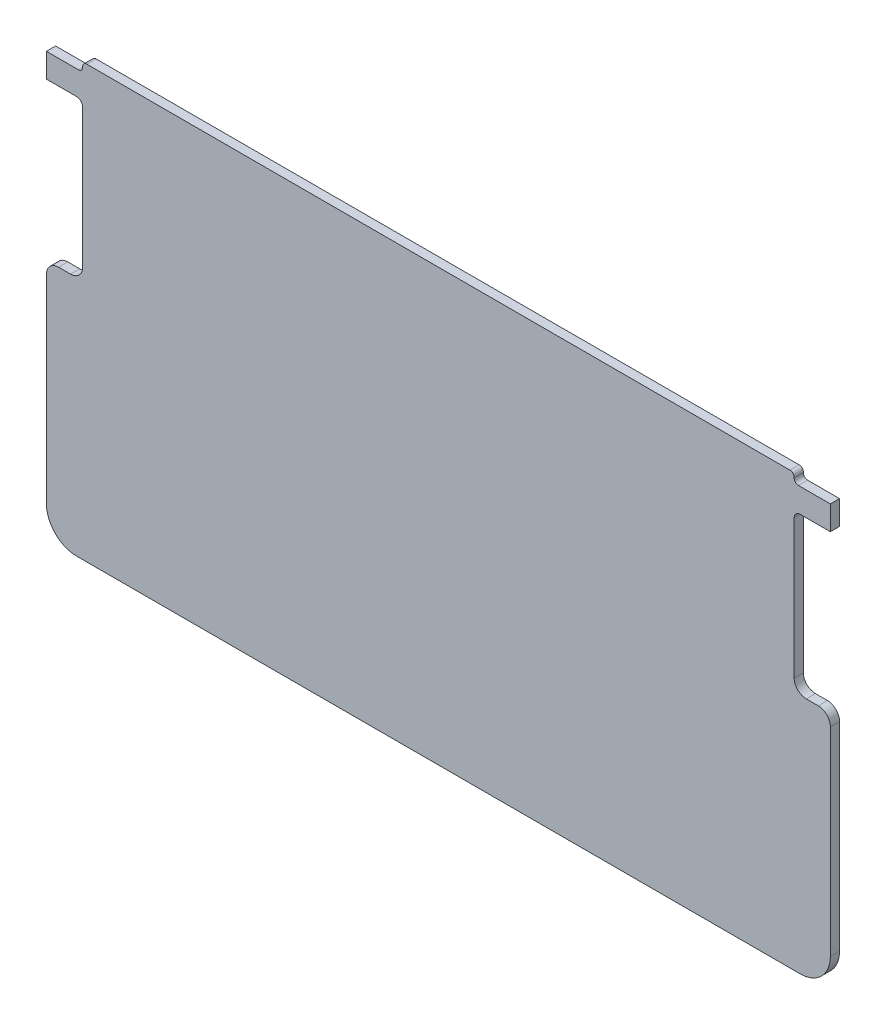
from build123d import *

# Parameters (mm, degrees)
BOSS_EXTRUDE1_DEPTH      = 0.381
BOSS_EXTRUDE1_DEPTH_BACK = 0.381


with BuildPart() as part:
    # Sketch1 → Boss-Extrude1 (new body, two sides)
    with BuildSketch(Plane.XY) as boss_extrude1_sk:
        with BuildLine():
            Line((-29.5, -34), (29.5, -34))
            Line((29.5, -34), (30, -34))
            ThreePointArc((30, -34), (31.767766953, -33.267766953), (32.5, -31.5))
            Line((32.5, -31.5), (32.5, -15))
            ThreePointArc((32.5, -15), (32.207106781, -14.292893219), (31.5, -14))
            Line((31.5, -14), (30.5, -14))
            ThreePointArc((30.5, -14), (29.792893219, -13.707106781), (29.5, -13))
            Line((29.5, -13), (29.5, -1.5))
            ThreePointArc((29.5, -1.5), (29.646446609, -1.146446609), (30, -1))
            Line((30, -1), (32.5, -1))
            Line((32.5, -1), (32.5, 1))
            Line((32.5, 1), (29.85, 1))
            ThreePointArc((29.85, 1), (29.602512627, 1.102512627), (29.5, 1.35))
            Line((29.5, 1.35), (29.5, 1.4))
            ThreePointArc((29.5, 1.4), (29.397487373, 1.647487373), (29.15, 1.75))
            Line((29.15, 1.75), (-29.15, 1.75))
            ThreePointArc((-29.15, 1.75), (-29.397487373, 1.647487373), (-29.5, 1.4))
            Line((-29.5, 1.4), (-29.5, 1.35))
            ThreePointArc((-29.5, 1.35), (-29.602512627, 1.102512627), (-29.85, 1))
            Line((-29.85, 1), (-32.5, 1))
            Line((-32.5, 1), (-32.5, -1))
            Line((-32.5, -1), (-30, -1))
            ThreePointArc((-30, -1), (-29.646446609, -1.146446609), (-29.5, -1.5))
            Line((-29.5, -1.5), (-29.5, -13))
            ThreePointArc((-29.5, -13), (-29.792893219, -13.707106781), (-30.5, -14))
            Line((-30.5, -14), (-31.5, -14))
            ThreePointArc((-31.5, -14), (-32.207106781, -14.292893219), (-32.5, -15))
            Line((-32.5, -15), (-32.5, -31.5))
            ThreePointArc((-32.5, -31.5), (-31.767766953, -33.267766953), (-30, -34))
            Line((-30, -34), (-29.5, -34))
        make_face()
    extrude(amount=BOSS_EXTRUDE1_DEPTH)
    extrude(boss_extrude1_sk.sketch, amount=-BOSS_EXTRUDE1_DEPTH_BACK)


solid = part.part
